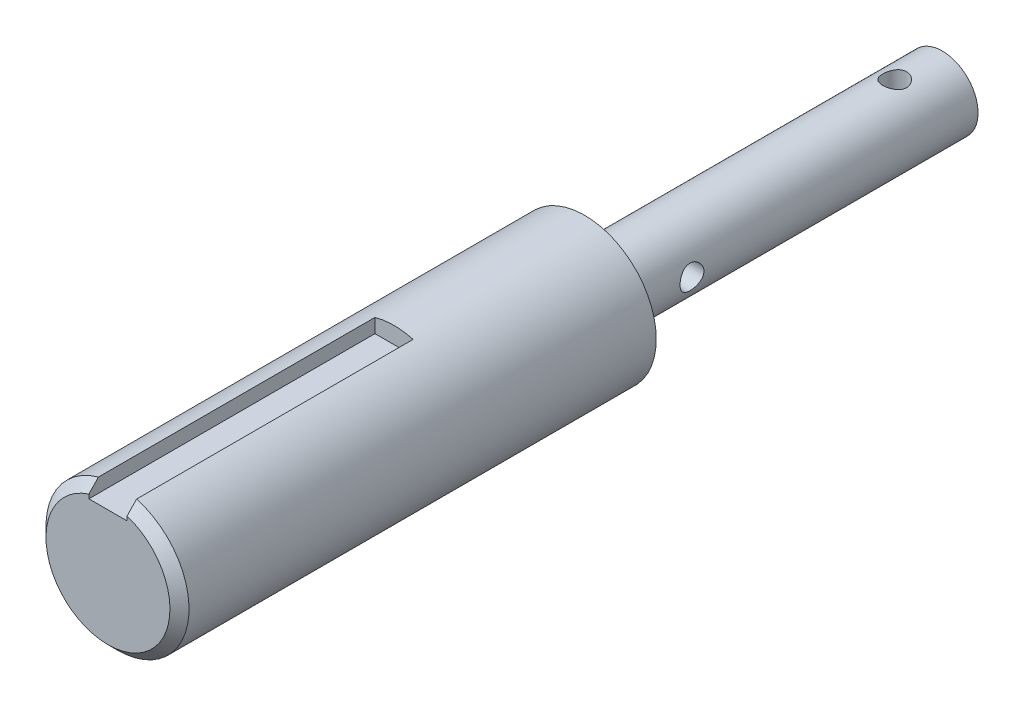
from build123d import *

# Parameters (mm, degrees)
SKETCH1_R               = 15
BOSS_EXTRUDE1_DEPTH     = 100
SKETCH2_W               = 8
SKETCH2_H               = 7
CUT_EXTRUDE1_DEPTH      = 60
CHAMFER1_SIZE           = 2
SCALE1_SCALE            = 2
SKETCH3_R               = 15
BOSS_EXTRUDE2_DEPTH     = 150
SKETCH4_R               = 5
CUT_EXTRUDE2_DEPTH      = 31.301047562
CUT_EXTRUDE2_DEPTH_BACK = 30.698952438
SKETCH5_R               = 5
CUT_EXTRUDE3_DEPTH      = 31
CUT_EXTRUDE3_DEPTH_BACK = 31


with BuildPart() as part:
    # Sketch1 → Boss-Extrude1 (new body)
    with BuildSketch(Plane.XY):
        Circle(SKETCH1_R)
    extrude(amount=BOSS_EXTRUDE1_DEPTH)

    # Sketch2 → Cut-Extrude1 (cut)
    with BuildSketch(Plane.XY.offset(100)):
        with Locations((0, 15)):
            Rectangle(SKETCH2_W, SKETCH2_H)
    extrude(amount=-CUT_EXTRUDE1_DEPTH, mode=Mode.SUBTRACT)

    # Chamfer1
    chamfer1_edges = [part.edges().sort_by_distance(p)[0] for p in [
        (-9.082951062, -11.937336386, 100),
    ]]
    chamfer(chamfer1_edges, length=CHAMFER1_SIZE)


with BuildPart() as part_1:
    # Scale1: scaled about (0, -0.301047562, 49.420279713)
    add(part.part.scale(SCALE1_SCALE).moved(Location((0, 0.301047562, -49.420279713))))

    # Sketch3 → Boss-Extrude2 (add)
    with BuildSketch(Plane(origin=(0, 0, -49.420279708), x_dir=(-1, 0, 0), z_dir=(0, 0, -1))):
        Circle(SKETCH3_R)
    extrude(amount=BOSS_EXTRUDE2_DEPTH)

    # Sketch4 → Cut-Extrude2 (cut, two sides)
    with BuildSketch(Plane(origin=(0, 0, 0), x_dir=(1, 0, 0), z_dir=(0, 1, 0))) as cut_extrude2_sk:
        with Locations((0, 179.420279708)):
            Circle(SKETCH4_R)
    extrude(amount=CUT_EXTRUDE2_DEPTH, mode=Mode.SUBTRACT)
    extrude(cut_extrude2_sk.sketch, amount=-CUT_EXTRUDE2_DEPTH_BACK, mode=Mode.SUBTRACT)

    # Sketch5 → Cut-Extrude3 (cut, two sides)
    with BuildSketch(Plane(origin=(0, 0, 0), x_dir=(0, 0, -1), z_dir=(1, 0, 0))) as cut_extrude3_sk:
        with Locations((79.420279708, 0)):
            Circle(SKETCH5_R)
    extrude(amount=CUT_EXTRUDE3_DEPTH, mode=Mode.SUBTRACT)
    extrude(cut_extrude3_sk.sketch, amount=-CUT_EXTRUDE3_DEPTH_BACK, mode=Mode.SUBTRACT)


solid = part_1.part
